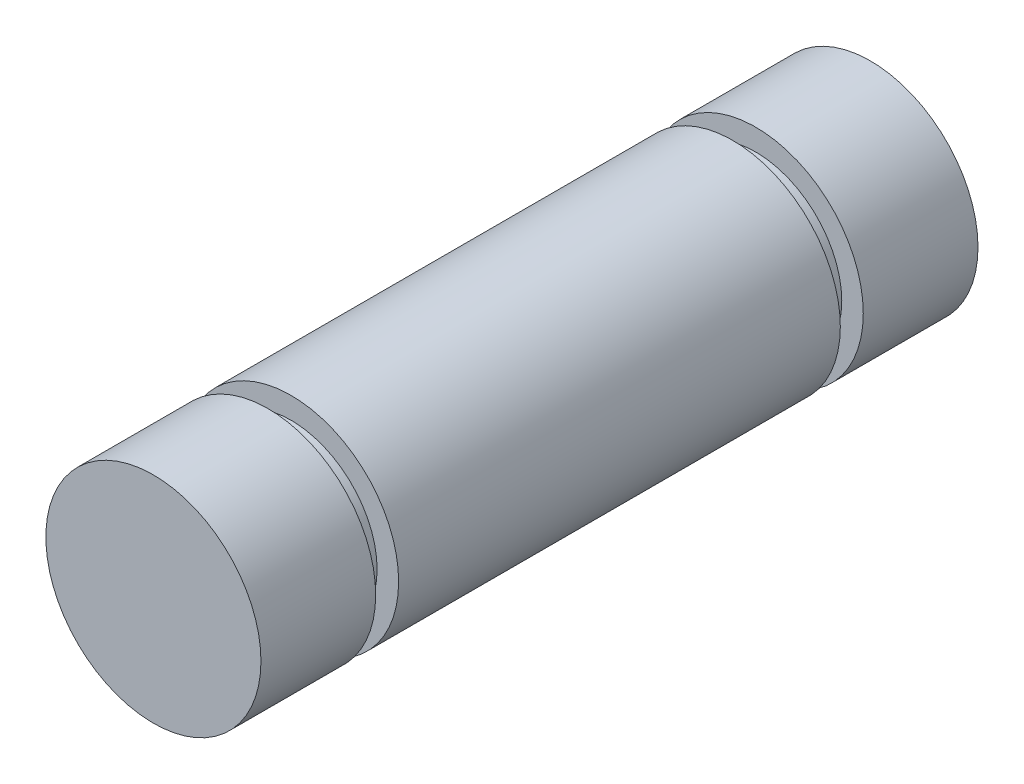
from build123d import *

# Parameters (mm, degrees)
SKETCH1_R           = 4.7625
BOSS_EXTRUDE1_DEPTH = 15.875
SKETCH2_W           = 0.9525
SKETCH2_H           = 1.016


with BuildPart() as part:
    # Sketch1 → Boss-Extrude1 (new body, symmetric)
    with BuildSketch(Plane.XY):
        Circle(SKETCH1_R)
    extrude(amount=BOSS_EXTRUDE1_DEPTH, both=True)

    # Sketch2 → Cut-Revolve1 (revolve, cut)
    with BuildSketch(Plane(origin=(0, 0, 0), x_dir=(1, 0, 0), z_dir=(0, 1, 0))):
        with Locations((4.28625, 10.287)):
            Rectangle(SKETCH2_W, SKETCH2_H)
        with Locations((4.28625, -10.287)):
            Rectangle(SKETCH2_W, SKETCH2_H)
    revolve(axis=Axis((0, 0, 15.875), (0, 0, -1)), mode=Mode.SUBTRACT)


solid = part.part
